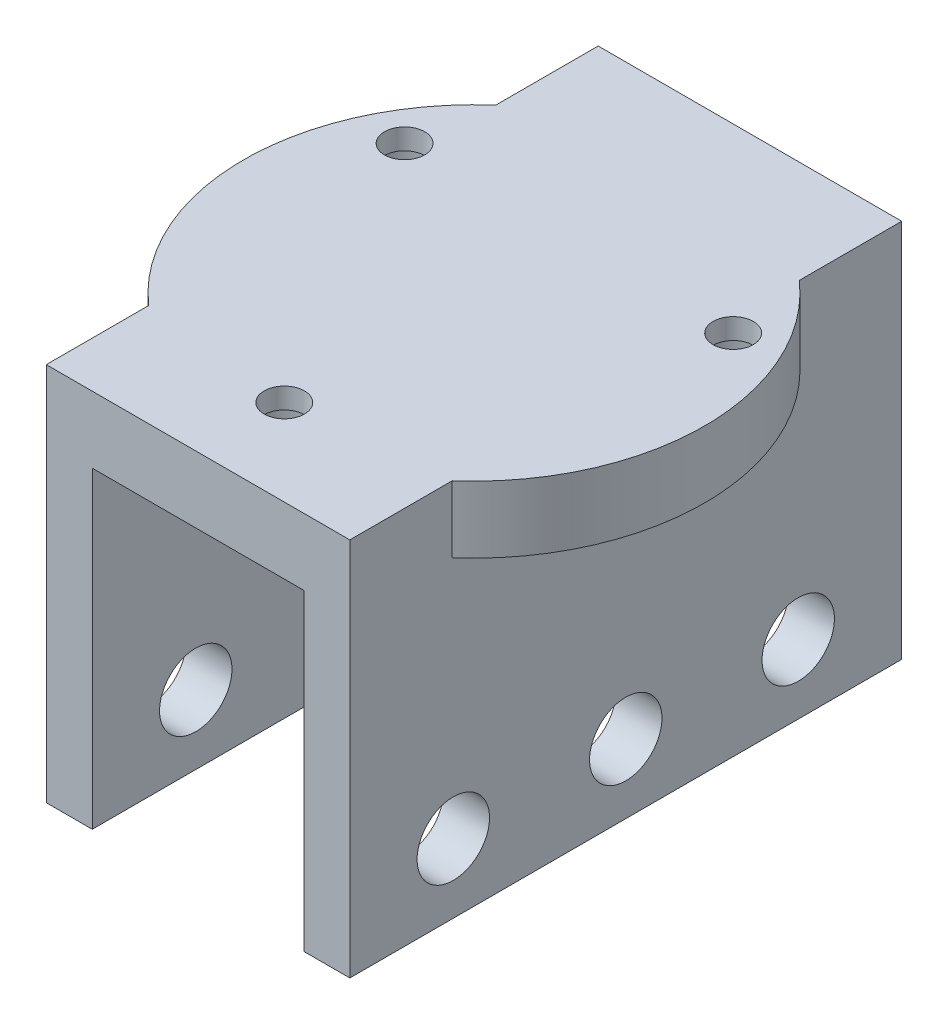
from build123d import *

# Parameters (mm, degrees)
EXTRUDE_1_DEPTH     = 24
SKETCH_3_R          = 3.15
CUT_EXTRUDE_2_DEPTH = 26.4
SKETCH_4_R          = 20.05
EXTRUDE_2_DEPTH     = 5.8
SKETCH_5_R          = 1.75
CUT_EXTRUDE_3_DEPTH = 5.8
SKETCH_6_R          = 3.1
CUT_EXTRUDE_4_DEPTH = 4
SKETCH_6_3_R        = 3.1
CUT_EXTRUDE_5_DEPTH = 6


with BuildPart() as part:
    # 草圖1 → 填料-伸長1 (new body, symmetric)
    with BuildSketch(Plane.XY):
        Polygon((0, 0), (0, 33), (26.4, 33), (26.4, 0), (22.4, 0), (22.4, 27.2), (4, 27.2), (4, 0), align=None)
    extrude(amount=EXTRUDE_1_DEPTH, both=True)

    # 草圖3 → 除料-伸長2 (cut)
    with BuildSketch(Plane(origin=(26.4, 0, 0), x_dir=(0, 0, -1), z_dir=(1, 0, 0))):
        with Locations((0, 6)):
            Circle(SKETCH_3_R)
        with Locations((15, 6)):
            Circle(SKETCH_3_R)
        with Locations((-15, 6)):
            Circle(SKETCH_3_R)
    extrude(amount=-CUT_EXTRUDE_2_DEPTH, mode=Mode.SUBTRACT)

    # 草圖4 → 填料-伸長2 (add)
    with BuildSketch(Plane(origin=(0, 33, 0), x_dir=(1, 0, 0), z_dir=(0, 1, 0))):
        with Locations((13.2, 0)):
            Circle(SKETCH_4_R)
    extrude(amount=-EXTRUDE_2_DEPTH)

    # 草圖5 → 除料-伸長3 (cut)
    with BuildSketch(Plane(origin=(0, 33, 0), x_dir=(1, 0, 0), z_dir=(0, 1, 0))):
        with Locations((13.2, -16.5)):
            Circle(SKETCH_5_R)
        with Locations((-1.089419162, 8.25)):
            Circle(SKETCH_5_R)
        with Locations((27.489419162, 8.25)):
            Circle(SKETCH_5_R)
    extrude(amount=-CUT_EXTRUDE_3_DEPTH, mode=Mode.SUBTRACT)

    # 草圖6 → 除料-伸長4 (cut)
    with BuildSketch(Plane.XZ.offset(-27.2)):
        with Locations((-1.089419162, -8.25)):
            Circle(SKETCH_6_R)
        with Locations((13.2, 16.5)):
            Circle(SKETCH_6_R)
        with Locations((27.489419162, -8.25)):
            Circle(SKETCH_6_R)
    extrude(amount=-CUT_EXTRUDE_4_DEPTH, mode=Mode.SUBTRACT)

    # 草圖6<3> → 除料-伸長5 (cut)
    with BuildSketch(Plane.XZ.offset(-27.2)):
        with Locations((-1.089419162, -8.25)):
            Circle(SKETCH_6_3_R)
        with Locations((27.489419162, -8.25)):
            Circle(SKETCH_6_3_R)
    extrude(amount=CUT_EXTRUDE_5_DEPTH, mode=Mode.SUBTRACT)


solid = part.part
